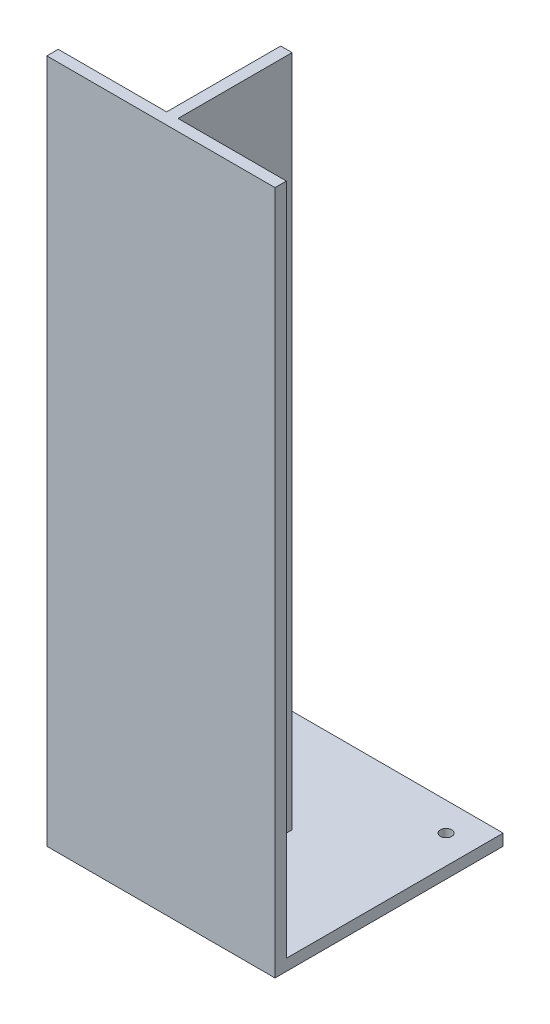
from build123d import *

# Parameters (mm, degrees)
SALIENTE_EXTRUIR1_DEPTH    = 200
SALIENTE_EXTRUIR2_DEPTH    = 590.35443
CROQUIS6_R                 = 5
CORTAR_EXTRUIR1_DEPTH      = 591.35443038
CORTAR_EXTRUIR1_DEPTH_BACK = 10.64556962


with BuildPart() as part:
    # Croquis2 → Saliente-Extruir1 (new body)
    with BuildSketch(Plane(origin=(0, 0, 0), x_dir=(0, 0, -1), z_dir=(1, 0, 0))):
        Polygon((0, 293.35443038), (0, -306.64556962), (200, -306.64556962), (200, -296.64556962), (10, -296.64556962), (10, 293.35443038), align=None)
    extrude(amount=-SALIENTE_EXTRUIR1_DEPTH)

    # Croquis5 → Saliente-Extruir2 (add, through all)
    with BuildSketch(Plane(origin=(0, -297, 0), x_dir=(1, 0, 0), z_dir=(0, 1, 0))):
        Polygon((-100, 10), (-105, 10), (-105, 110), (-95, 110), (-95, 10), align=None)
    extrude(amount=SALIENTE_EXTRUIR2_DEPTH)

    # Croquis6 → Cortar-Extruir1 (cut, two sides)
    with BuildSketch(Plane(origin=(0, -297, 0), x_dir=(1, 0, 0), z_dir=(0, 1, 0))) as cortar_extruir1_sk:
        with Locations((-175, 175)):
            Circle(CROQUIS6_R)
        with Locations((-25, 175)):
            Circle(CROQUIS6_R)
        with Locations((-25, 25)):
            Circle(CROQUIS6_R)
        with Locations((-175, 25)):
            Circle(CROQUIS6_R)
    extrude(amount=CORTAR_EXTRUIR1_DEPTH, mode=Mode.SUBTRACT)
    extrude(cortar_extruir1_sk.sketch, amount=-CORTAR_EXTRUIR1_DEPTH_BACK, mode=Mode.SUBTRACT)


solid = part.part
